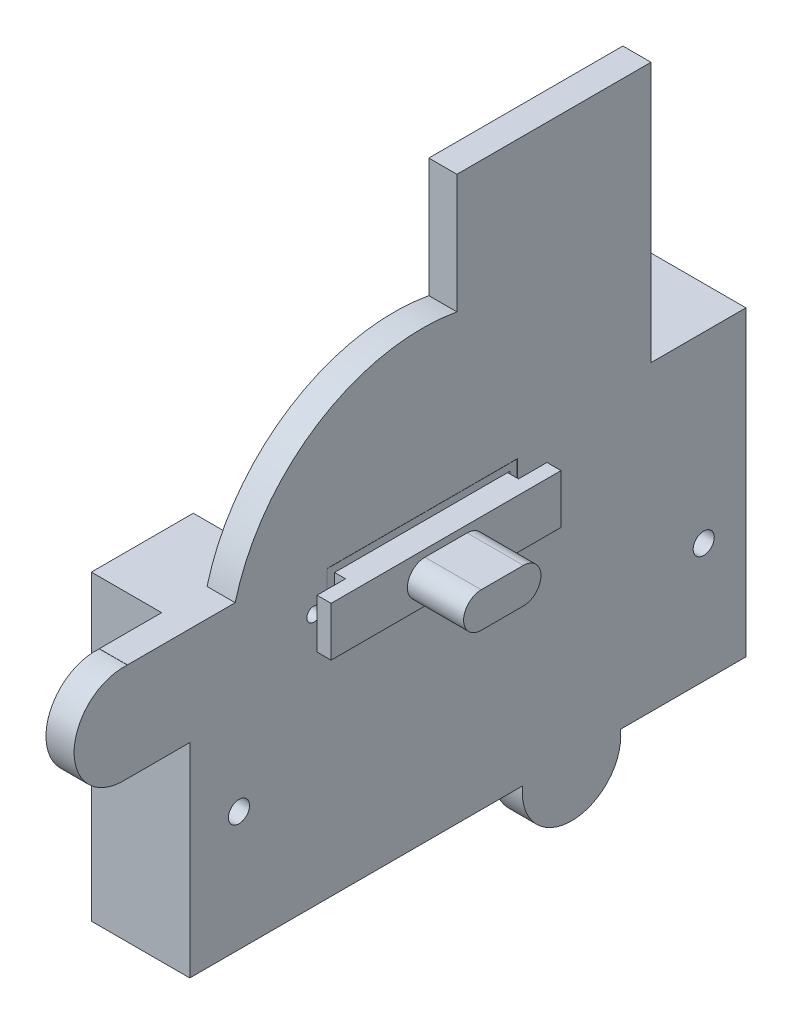
from build123d import *

# Parameters (mm, degrees)
SKETCH1_R            = 1.5
BOSS_EXTRUDE1_DEPTH  = 4
SKETCH2_W            = 27.1
SKETCH2_H            = 9.35
CUT_EXTRUDE1_DEPTH   = 5
SKETCH3_R            = 1
CUT_EXTRUDE2_DEPTH   = 5
SKETCH4_W            = 14.5
SKETCH4_H            = 43
SKETCH4_R            = 1.5
BOSS_EXTRUDE2_DEPTH  = 10
SKETCH5_W            = 35
SKETCH5_H            = 9.3
SKETCH5_R            = 1
BOSS_EXTRUDE3_DEPTH  = 2
SKETCH6_W            = 27
SKETCH6_H            = 9.3
SKETCH6_W_2          = 25
SKETCH6_H_2          = 7.3
BOSS_EXTRUDE4_DEPTH  = 4
BOSS_EXTRUDE5_DEPTH  = 8
SKETCH8_W            = 39.1
SKETCH8_H            = 13.35
SKETCH8_W_2          = 35.1
SKETCH8_H_2          = 9.35
BOSS_EXTRUDE6_DEPTH  = 2
SKETCH10_W           = 25
SKETCH10_H           = 7.3
BOSS_EXTRUDE7_DEPTH  = 1.3
SKETCH11_W           = 24.6
SKETCH11_H           = 7
BOSS_EXTRUDE8_DEPTH  = 4.1
SKETCH12_W           = 32.7
SKETCH12_H           = 7
BOSS_EXTRUDE9_DEPTH  = 2
BOSS_EXTRUDE10_DEPTH = 8
SKETCH15_W           = 27.6
SKETCH15_H           = 37
BOSS_EXTRUDE11_DEPTH = 4
BOSS_EXTRUDE12_DEPTH = 4
BOSS_EXTRUDE13_START = -4
BOSS_EXTRUDE13_DEPTH = 4


with BuildPart() as part:
    # Sketch1 → Boss-Extrude1 (new body)
    with BuildSketch(Plane(origin=(0, 0, 0), x_dir=(0, 0, -1), z_dir=(1, 0, 0))):
        Polygon((39.05, 17), (39.05, -17), (-40.05, -17), (-40.05, 17), (-40.05, 26), (39.05, 26), align=None)
        with Locations((-33.05, 0)):
            Circle(SKETCH1_R, mode=Mode.SUBTRACT)
        with Locations((33.05, 0)):
            Circle(SKETCH1_R, mode=Mode.SUBTRACT)
    extrude(amount=BOSS_EXTRUDE1_DEPTH)

    # Sketch2 → Cut-Extrude1 (cut, through all)
    with BuildSketch(Plane(origin=(4, 0, 0), x_dir=(0, 0, -1), z_dir=(1, 0, 0))):
        with Locations((-7, 19)):
            Rectangle(SKETCH2_W, SKETCH2_H)
    extrude(amount=-CUT_EXTRUDE1_DEPTH, mode=Mode.SUBTRACT)

    # Sketch3 → Cut-Extrude2 (cut, through all)
    with BuildSketch(Plane(origin=(4, 0, 0), x_dir=(0, 0, -1), z_dir=(1, 0, 0))):
        with Locations((-22.4, 19)):
            Circle(SKETCH3_R)
        with Locations((8.4, 19)):
            Circle(SKETCH3_R)
    extrude(amount=-CUT_EXTRUDE2_DEPTH, mode=Mode.SUBTRACT)

    # Sketch4 → Boss-Extrude2 (add)
    with BuildSketch(Plane.ZY):
        with Locations((-31.8, 4.5)):
            Rectangle(SKETCH4_W, SKETCH4_H)
        with Locations((-33.05, 0)):
            Circle(SKETCH4_R, mode=Mode.SUBTRACT)
        with Locations((32.8, 4.5)):
            Rectangle(SKETCH4_W, SKETCH4_H)
        with Locations((33.05, 0)):
            Circle(SKETCH4_R, mode=Mode.SUBTRACT)
    extrude(amount=BOSS_EXTRUDE2_DEPTH)

    # Sketch8 → Boss-Extrude6 (add)
    with BuildSketch(Plane.ZY):
        with Locations((7, 19)):
            Rectangle(SKETCH8_W, SKETCH8_H)
        with Locations((7, 19)):
            Rectangle(SKETCH8_W_2, SKETCH8_H_2, mode=Mode.SUBTRACT)
    extrude(amount=BOSS_EXTRUDE6_DEPTH)

    # Sketch15 → Boss-Extrude11 (add)
    with BuildSketch(Plane(origin=(4, 0, 0), x_dir=(0, 0, -1), z_dir=(1, 0, 0))):
        with Locations((11.75, 44.5)):
            Rectangle(SKETCH15_W, SKETCH15_H)
    extrude(amount=-BOSS_EXTRUDE11_DEPTH)

    # Sketch16 → Boss-Extrude12 (add)
    with BuildSketch(Plane(origin=(4, 0, 0), x_dir=(0, 0, -1), z_dir=(1, 0, 0))):
        with BuildLine():
            Line((-33.594172294, 26), (-2.05, 26))
            Line((-2.05, 26), (-2.05, 46.05083178))
            ThreePointArc((-2.05, 46.05083178), (-21.75216975, 42.208263349), (-33.594172294, 26))
        make_face()
    extrude(amount=-BOSS_EXTRUDE12_DEPTH)

    # Sketch17 → Boss-Extrude13 (add)
    with BuildSketch(Plane(origin=(4, 0, 0), x_dir=(0, 0, -1), z_dir=(1, 0, 0)).offset(BOSS_EXTRUDE13_START)):
        with BuildLine():
            ThreePointArc((-48.923529412, 25.976222593), (-56.5, 19), (-48.923529412, 12.023777407))
            ThreePointArc((-48.923529412, 12.023777407), (-48.92154931, 12.011888423), (-48.919565837, 12))
            Line((-48.919565837, 12), (-40.05, 12))
            Line((-40.05, 12), (-40.05, 26))
            Line((-40.05, 26), (-48.919565837, 26))
            ThreePointArc((-48.919565837, 26), (-48.92154931, 25.988111577), (-48.923529412, 25.976222593))
        make_face()
        with BuildLine():
            ThreePointArc((7.296566634, -17), (14.25, -24.806079661), (21.203433366, -17))
            Line((21.203433366, -17), (7.296566634, -17))
        make_face()
    extrude(amount=BOSS_EXTRUDE13_DEPTH)


with BuildPart() as body_2:
    # Sketch5 → Boss-Extrude3 (new body)
    with BuildSketch(Plane.ZY):
        with Locations((7, 19)):
            Rectangle(SKETCH5_W, SKETCH5_H)
        with Locations((-8.4, 19)):
            Circle(SKETCH5_R, mode=Mode.SUBTRACT)
        with Locations((22.4, 19)):
            Circle(SKETCH5_R, mode=Mode.SUBTRACT)
    extrude(amount=BOSS_EXTRUDE3_DEPTH)

    # Sketch6 → Boss-Extrude4 (add)
    with BuildSketch(Plane(origin=(0, 0, 0), x_dir=(0, 0, -1), z_dir=(1, 0, 0))):
        with Locations((-7, 19)):
            Rectangle(SKETCH6_W, SKETCH6_H)
        with Locations((-7, 19)):
            Rectangle(SKETCH6_W_2, SKETCH6_H_2, mode=Mode.SUBTRACT)
    extrude(amount=BOSS_EXTRUDE4_DEPTH)

    # Sketch7 → Boss-Extrude5 (add)
    with BuildSketch(Plane.ZY.offset(2)):
        with BuildLine():
            Line((4, 21.5), (10, 21.5))
            ThreePointArc((10, 21.5), (12.5, 19), (10, 16.5))
            Line((10, 16.5), (4, 16.5))
            ThreePointArc((4, 16.5), (1.5, 19), (4, 21.5))
        make_face()
    extrude(amount=BOSS_EXTRUDE5_DEPTH)

    # Sketch10 → Boss-Extrude7 (add)
    with BuildSketch(Plane(origin=(0, 0, 0), x_dir=(0, 0, -1), z_dir=(1, 0, 0))):
        with Locations((-7, 19)):
            Rectangle(SKETCH10_W, SKETCH10_H)
    extrude(amount=BOSS_EXTRUDE7_DEPTH)


with BuildPart() as body_3:
    # Sketch11 → Boss-Extrude8 (new body)
    with BuildSketch(Plane(origin=(1.3, 0, 0), x_dir=(0, 0, -1), z_dir=(1, 0, 0))):
        with Locations((-7, 19)):
            Rectangle(SKETCH11_W, SKETCH11_H)
    extrude(amount=BOSS_EXTRUDE8_DEPTH)

    # Sketch12 → Boss-Extrude9 (add)
    with BuildSketch(Plane(origin=(5.4, 0, 0), x_dir=(0, 0, -1), z_dir=(1, 0, 0))):
        with Locations((-7, 19)):
            Rectangle(SKETCH12_W, SKETCH12_H)
    extrude(amount=BOSS_EXTRUDE9_DEPTH)

    # Sketch13 → Boss-Extrude10 (add)
    with BuildSketch(Plane(origin=(7.4, 0, 0), x_dir=(0, 0, -1), z_dir=(1, 0, 0))):
        with BuildLine():
            Line((-10, 16.5), (-4, 16.5))
            ThreePointArc((-4, 16.5), (-1.5, 19), (-4, 21.5))
            Line((-4, 21.5), (-10, 21.5))
            ThreePointArc((-10, 21.5), (-12.5, 19), (-10, 16.5))
        make_face()
    extrude(amount=BOSS_EXTRUDE10_DEPTH)


solid = Compound([part.part, body_2.part, body_3.part])
